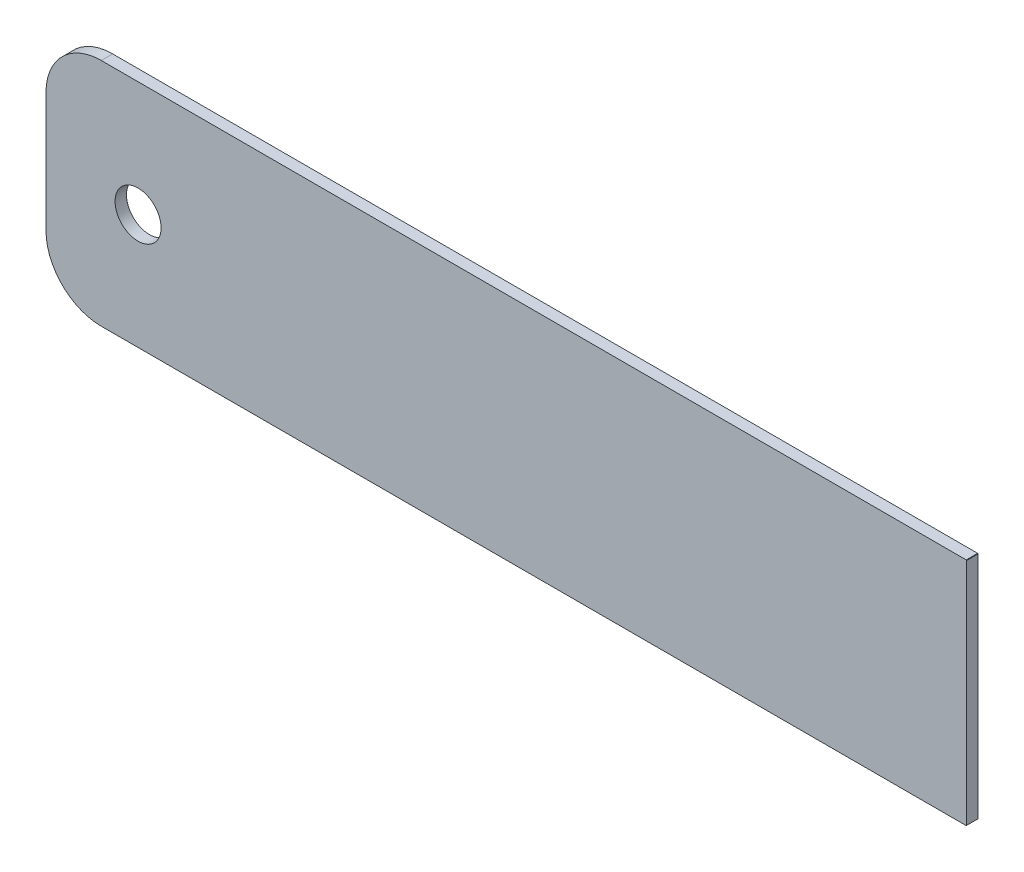
from build123d import *

# Parameters (mm, degrees)
SKETCH1_R      = 1.5875
EXTRUDE1_DEPTH = 0.7874


with BuildPart() as part:
    # Sketch1 → Extrude1 (new body)
    with BuildSketch(Plane.XY):
        with BuildLine():
            Line((0, 15.8496), (-0.0254, 15.875))
            Line((-0.0254, 15.875), (-59.69, 15.875))
            ThreePointArc((-59.69, 15.875), (-62.384076836, 14.759076836), (-63.5, 12.065))
            Line((-63.5, 12.065), (-63.5, 3.81))
            ThreePointArc((-63.5, 3.81), (-62.384076836, 1.115923164), (-59.69, 0))
            Line((-59.69, 0), (-0.0254, 0))
            Line((-0.0254, 0), (0, 0.0254))
            Line((0, 0.0254), (0, 15.8496))
        make_face()
        with Locations((-57.15, 7.9375)):
            Circle(SKETCH1_R, mode=Mode.SUBTRACT)
    extrude(amount=EXTRUDE1_DEPTH)


solid = part.part
